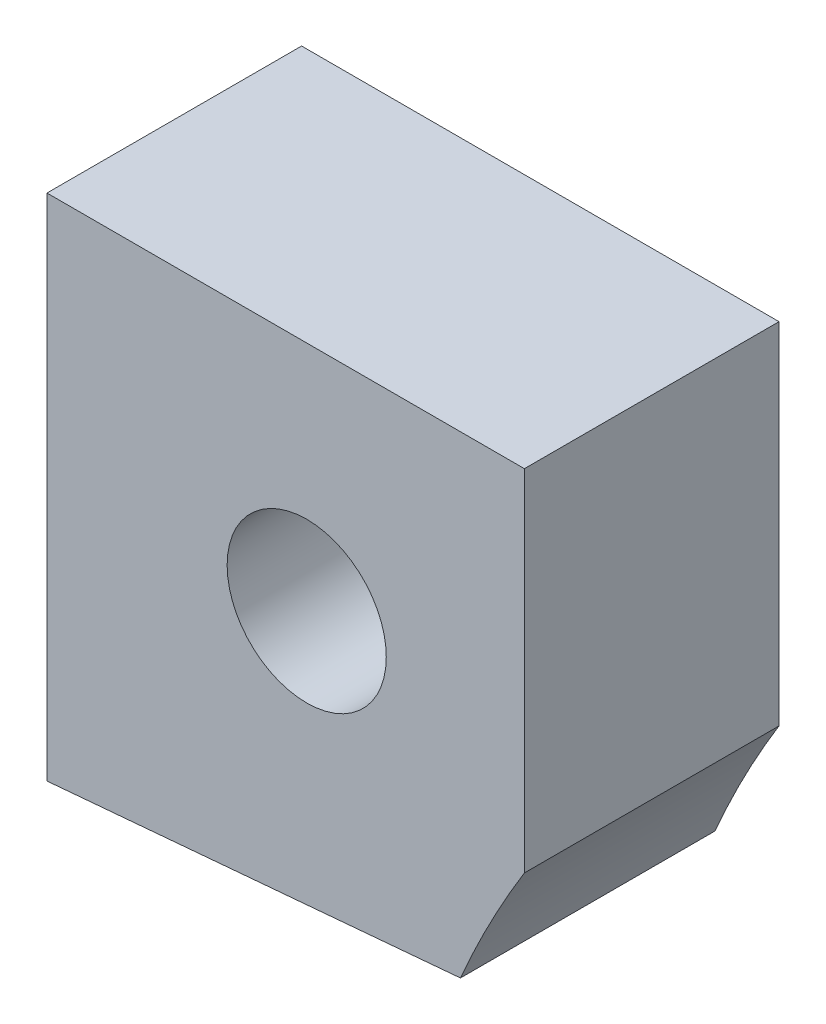
from build123d import *

# Parameters (mm, degrees)
SKETCH_1_R          = 1.5
EXTRUDE_1_DEPTH     = 8
SKETCH_2_R          = 2.5
CUT_EXTRUDE_1_DEPTH = 4


with BuildPart() as part:
    # 草图1 → 凸台-拉伸1 (new body)
    with BuildSketch(Plane.XY):
        with BuildLine():
            Line((26.30677697, 11), (26.30677697, 0))
            ThreePointArc((26.30677697, 0), (25.231575927, -1.895238991), (24.29677697, -3.863522261))
            Line((24.29677697, -3.863522261), (11.30677697, -5))
            Line((11.30677697, -5), (11.30677697, 11))
            Line((11.30677697, 11), (26.30677697, 11))
        make_face()
        with Locations((19.467365682, 3.704627959)):
            Circle(SKETCH_1_R, mode=Mode.SUBTRACT)
    extrude(amount=EXTRUDE_1_DEPTH)

    # 草图2 → 切除-拉伸1 (cut)
    with BuildSketch(Plane.XY.offset(8)):
        with Locations((19.467365682, 3.704627959)):
            Circle(SKETCH_2_R)
    extrude(amount=-CUT_EXTRUDE_1_DEPTH, mode=Mode.SUBTRACT)


solid = part.part
